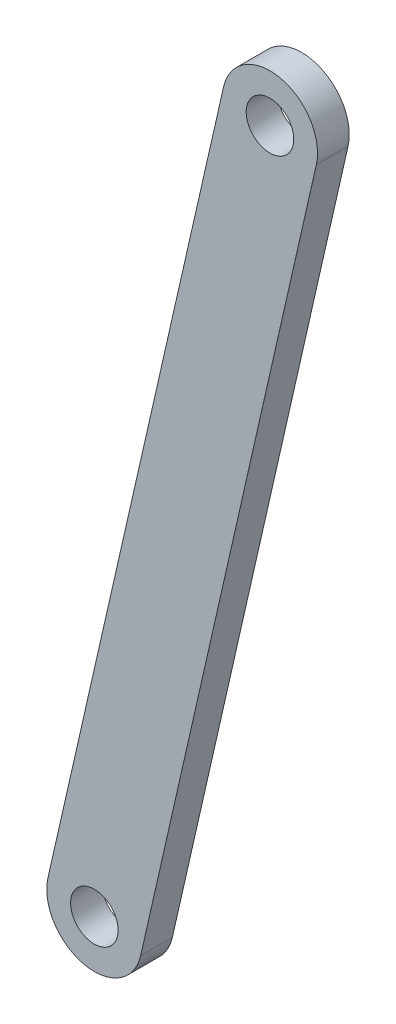
from build123d import *

# Parameters (mm, degrees)
SKETCH2_R           = 7.5
BOSS_EXTRUDE1_DEPTH = 10


with BuildPart() as part:
    # Sketch2 → Boss-Extrude1 (new body)
    with BuildSketch(Plane.XY):
        with BuildLine():
            Line((-14.626992837, 3.324316554), (40.77828306, 247.107530502))
            ThreePointArc((40.77828306, 247.107530502), (58.729592451, 258.410206785), (70.032268734, 240.458897394))
            Line((70.032268734, 240.458897394), (14.626992837, -3.324316554))
            ThreePointArc((14.626992837, -3.324316554), (-3.324316554, -14.626992837), (-14.626992837, 3.324316554))
        make_face()
        Circle(SKETCH2_R, mode=Mode.SUBTRACT)
        with Locations((55.405275897, 243.783213948)):
            Circle(SKETCH2_R, mode=Mode.SUBTRACT)
    extrude(amount=BOSS_EXTRUDE1_DEPTH)


solid = part.part
